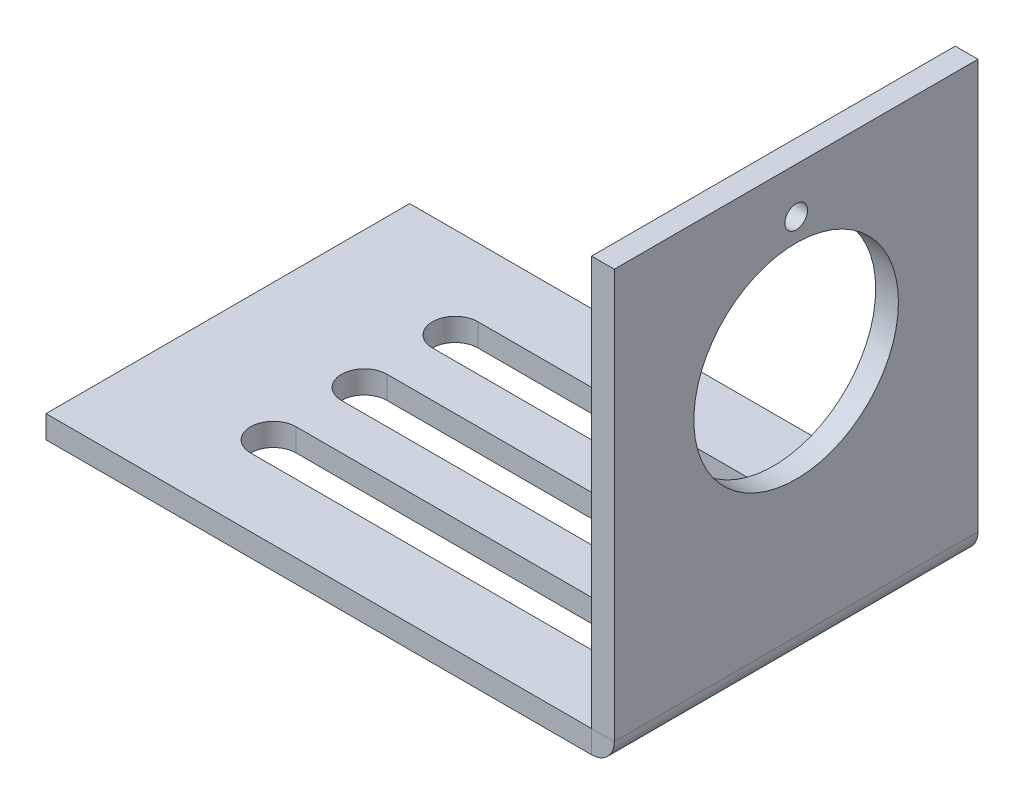
from build123d import *

# Parameters (mm, degrees)
SKETCH1_W           = 38.1
SKETCH1_H           = 25.4
BOSS_EXTRUDE1_DEPTH = 1.5875
SKETCH2_W           = 1.5875
SKETCH2_H           = 28.575
BOSS_EXTRUDE2_DEPTH = 25.4
BOSS_EXTRUDE3_DEPTH = 25.4
SKETCH4_R           = 7.14375
SKETCH4_R_2         = 0.79375
CUT_EXTRUDE1_DEPTH  = 25.4
CUT_EXTRUDE2_DEPTH  = 25.4
LPATTERN1_COUNT     = 3
LPATTERN1_PITCH     = 6.35


with BuildPart() as part:
    # Sketch1 → Boss-Extrude1 (new body)
    with BuildSketch(Plane(origin=(0, 0, 0), x_dir=(1, 0, 0), z_dir=(0, 1, 0))):
        Rectangle(SKETCH1_W, SKETCH1_H)
    extrude(amount=BOSS_EXTRUDE1_DEPTH)

    # Sketch5 → Cut-Extrude2 (cut)
    with BuildSketch(Plane(origin=(0, 1.5875, 0), x_dir=(1, 0, 0), z_dir=(0, 1, 0))):
        with BuildLine():
            Line((-9.525, -4.7625), (15.875, -4.7625))
            ThreePointArc((15.875, -4.7625), (17.4625, -6.35), (15.875, -7.9375))
            Line((15.875, -7.9375), (-9.525, -7.9375))
            ThreePointArc((-9.525, -7.9375), (-11.1125, -6.35), (-9.525, -4.7625))
        make_face()
    cut_extrude2 = extrude(amount=-CUT_EXTRUDE2_DEPTH, mode=Mode.SUBTRACT)

    # LPattern1: Cut-Extrude2 ×3
    with Locations(*[(0, 0, -i * LPATTERN1_PITCH) for i in range(1, LPATTERN1_COUNT)]):
        add(cut_extrude2, mode=Mode.SUBTRACT)


with BuildPart() as body_2:
    # Sketch2 → Boss-Extrude2 (new body)
    with BuildSketch(Plane.XY.offset(12.7)):
        with Locations((19.84375, 15.875)):
            Rectangle(SKETCH2_W, SKETCH2_H)
    extrude(amount=-BOSS_EXTRUDE2_DEPTH)

    # Sketch4 → Cut-Extrude1 (cut)
    with BuildSketch(Plane(origin=(20.6375, 0, 0), x_dir=(0, 0, -1), z_dir=(1, 0, 0))):
        with Locations((0, 18.25625)):
            Circle(SKETCH4_R)
        with Locations((0, 26.9875)):
            Circle(SKETCH4_R_2)
    extrude(amount=-CUT_EXTRUDE1_DEPTH, mode=Mode.SUBTRACT)


with BuildPart() as body_3:
    # Sketch3 → Boss-Extrude3 (new body)
    with BuildSketch(Plane.XY.offset(12.7)):
        with BuildLine():
            Line((20.6375, 1.5875), (19.05, 1.5875))
            Line((19.05, 1.5875), (19.05, 0))
            ThreePointArc((19.05, 0), (20.172532015, 0.464967985), (20.6375, 1.5875))
        make_face()
    extrude(amount=-BOSS_EXTRUDE3_DEPTH)


solid = Compound([part.part, body_2.part, body_3.part])
